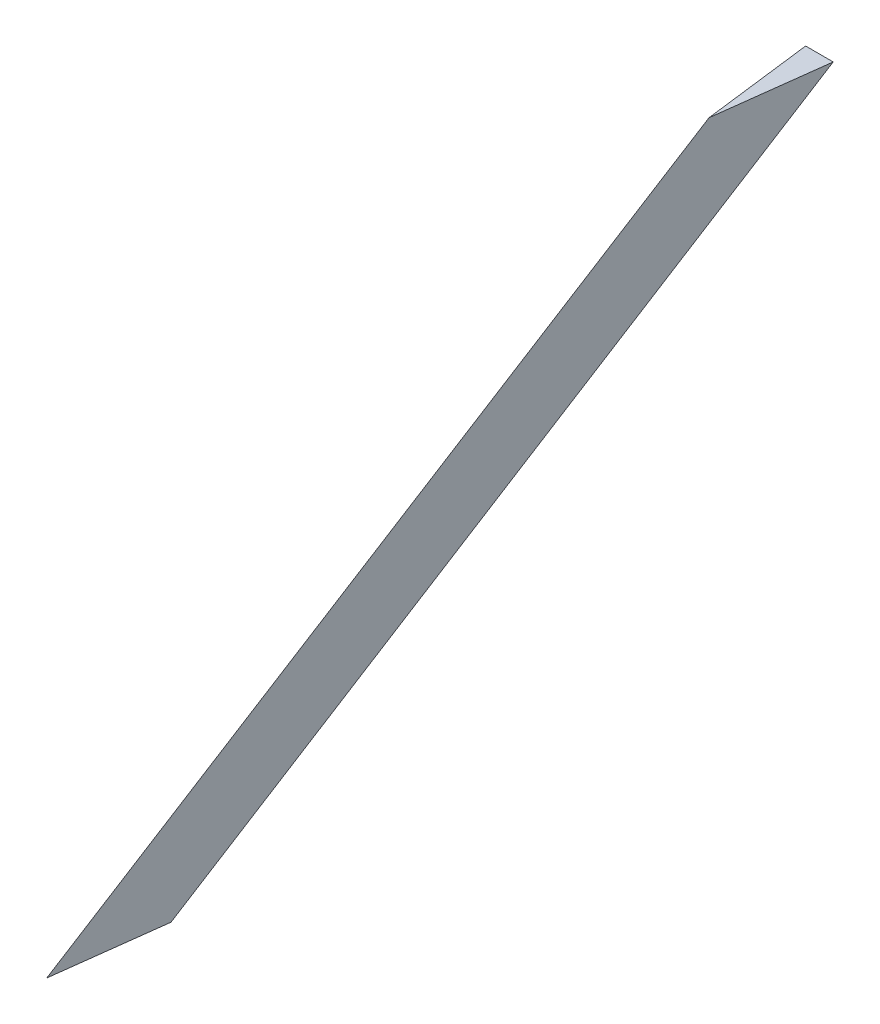
from build123d import *


with BuildPart() as part:
    # Sweep1: sweep along a path in Sketch1
    with BuildLine(Plane(origin=(0, 0, 0), x_dir=(0, 0, -1), z_dir=(1, 0, 0))) as sweep1_path:
        Line((0, 0), (152.4, 95.25))
    # Sketch2 → Sweep1 (sweep)
    with BuildSketch(Plane(origin=(0, 0, 0), x_dir=(1, 0, 0), z_dir=(0, 1, 0))):
        Polygon((0, -25.4), (-3.175, 0), (3.175, 0), align=None)
    sweep(path=sweep1_path.line)


solid = part.part
